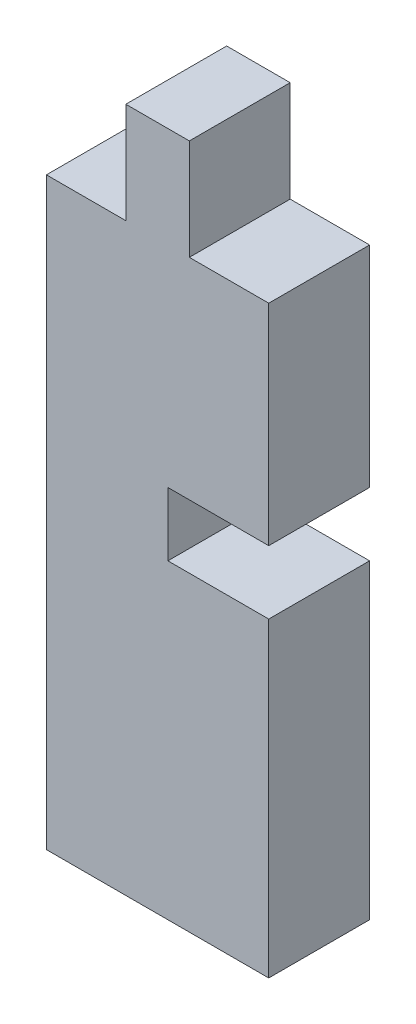
from build123d import *

# Parameters (mm, degrees)
BOSS_EXTRUDE1_DEPTH = 3.175


with BuildPart() as part:
    # Sketch1 → Boss-Extrude1 (new body)
    with BuildSketch(Plane.XY):
        Polygon((-3.5, -10.7874943), (3.5, -10.7874943), (3.5, -1), (0.325, -1), (0.325, 1), (3.5, 1), (3.5, 7.6124943), (1, 7.6124943), (1, 10.7874943), (-1, 10.7874943), (-1, 7.6124943), (-3.5, 7.6124943), align=None)
    extrude(amount=BOSS_EXTRUDE1_DEPTH)


solid = part.part
